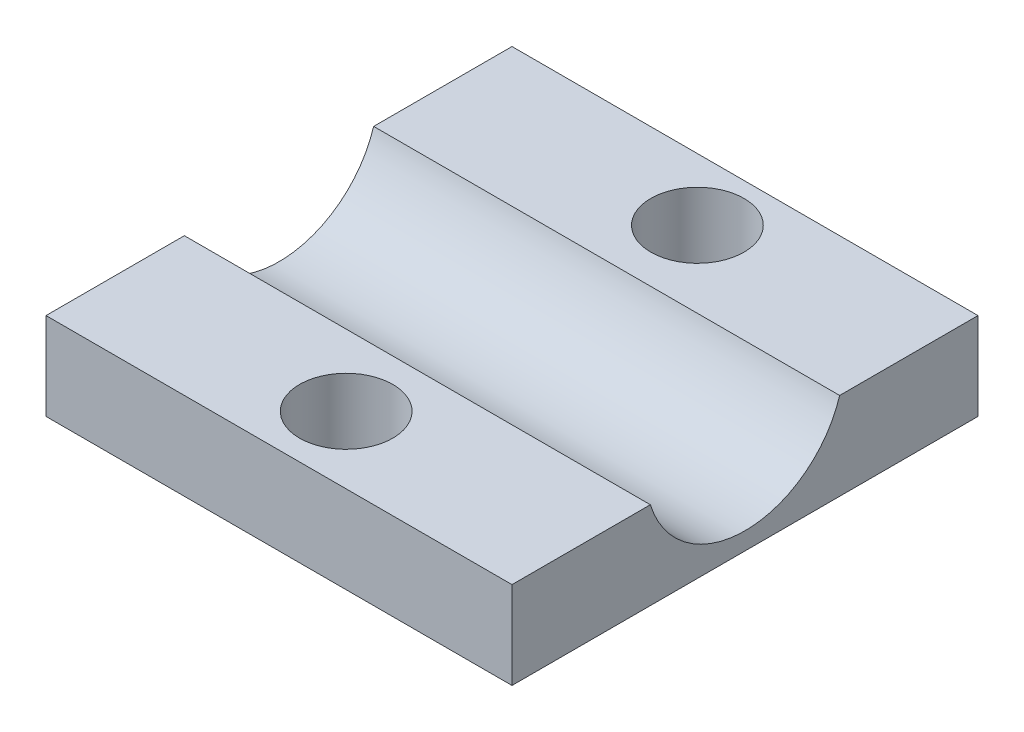
from build123d import *

# Parameters (mm, degrees)
SKETCH1_W                = 40
SKETCH1_H                = 40
BOSS_EXTRUDE1_DEPTH      = 7.5
CUT_EXTRUDE1_DEPTH       = 20
CUT_EXTRUDE1_DEPTH_BACK  = 20
SKETCH2_R                = 8.5
F_8_0_8_DIAMETER_HOLE1_D = 8


with BuildPart() as part:
    # Sketch1 → Boss-Extrude1 (new body)
    with BuildSketch(Plane(origin=(0, 0, 0), x_dir=(1, 0, 0), z_dir=(0, 1, 0))):
        Rectangle(SKETCH1_W, SKETCH1_H)
    extrude(amount=BOSS_EXTRUDE1_DEPTH)

    # Sketch2 → Cut-Extrude1 (cut, two sides: drawn at the far end of the back side and taken through both)
    with BuildSketch(Plane(origin=(0, 0, 0), x_dir=(0, 0, -1), z_dir=(1, 0, 0)).offset(-CUT_EXTRUDE1_DEPTH_BACK)):
        with Locations((0, 10)):
            Circle(SKETCH2_R)
    extrude(amount=CUT_EXTRUDE1_DEPTH + CUT_EXTRUDE1_DEPTH_BACK, mode=Mode.SUBTRACT)

    # Ø8.0 (8) Diameter Hole1 (through all)
    with Locations(Plane(origin=(0, 7.5, 0), x_dir=(1, 0, 0), z_dir=(0, 1, 0))):
        with Locations((1.247226864, 14.667228454), (0, -14.232771546)):
            Hole(F_8_0_8_DIAMETER_HOLE1_D / 2)


solid = part.part
